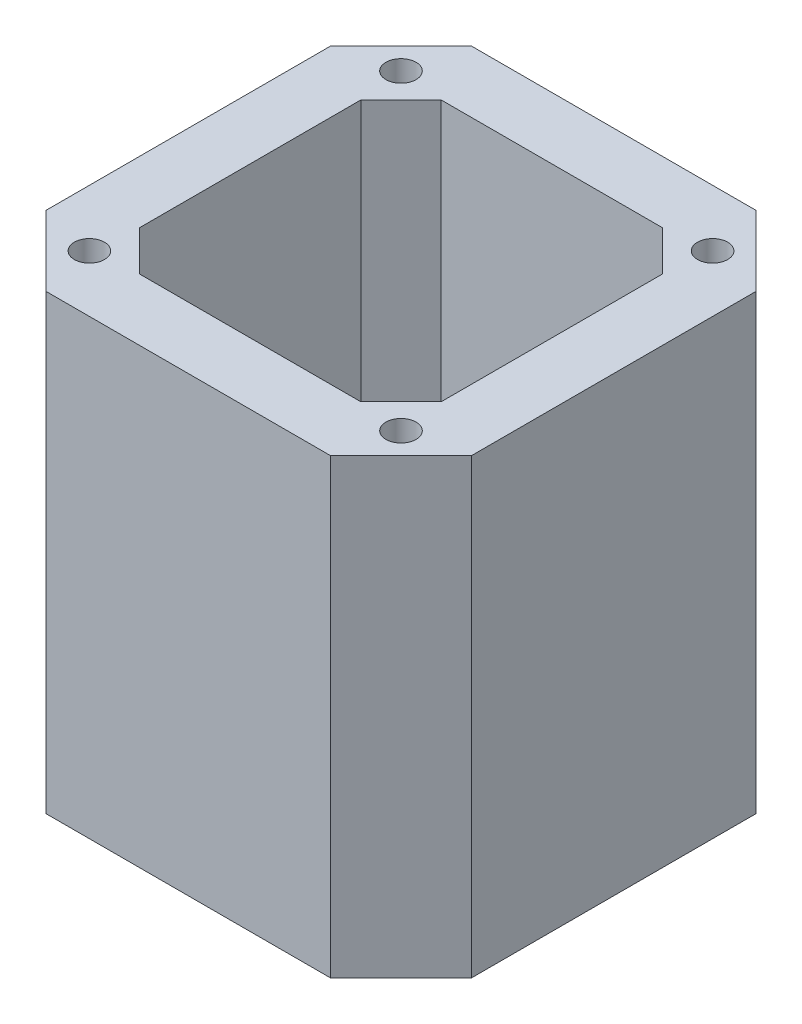
from build123d import *

# Parameters (mm, degrees)
BOSS_EXTRUDE1_DEPTH = 45
SKETCH2_R           = 1.5
CUT_EXTRUDE1_DEPTH  = 5
CUT_EXTRUDE3_DEPTH  = 45


with BuildPart() as part:
    # Sketch1 → Boss-Extrude1 (new body)
    with BuildSketch(Plane(origin=(0, 0, 0), x_dir=(1, 0, 0), z_dir=(0, 1, 0))):
        Polygon((-21.15, 14.15), (-14.15, 21.15), (14.15, 21.15), (21.15, 14.15), (21.15, -14.15), (14.15, -21.15), (-14.15, -21.15), (-21.15, -14.15), align=None)
    extrude(amount=BOSS_EXTRUDE1_DEPTH)

    # Sketch2 → Cut-Extrude1 (cut)
    with BuildSketch(Plane(origin=(0, 45, 0), x_dir=(1, 0, 0), z_dir=(0, 1, 0))):
        with Locations((-15.5, 15.5)):
            Circle(SKETCH2_R)
        with Locations((15.5, 15.5)):
            Circle(SKETCH2_R)
        with Locations((-15.5, -15.5)):
            Circle(SKETCH2_R)
        with Locations((15.5, -15.5)):
            Circle(SKETCH2_R)
    extrude(amount=-CUT_EXTRUDE1_DEPTH, mode=Mode.SUBTRACT)

    # Sketch3 → Cut-Extrude3 (cut)
    with BuildSketch(Plane(origin=(0, 45, 0), x_dir=(1, 0, 0), z_dir=(0, 1, 0))):
        Polygon((-15, 11), (-11, 15), (11, 15), (15, 11), (15, -11), (11, -15), (-11, -15), (-15, -11), align=None)
    extrude(amount=-CUT_EXTRUDE3_DEPTH, mode=Mode.SUBTRACT)


solid = part.part
